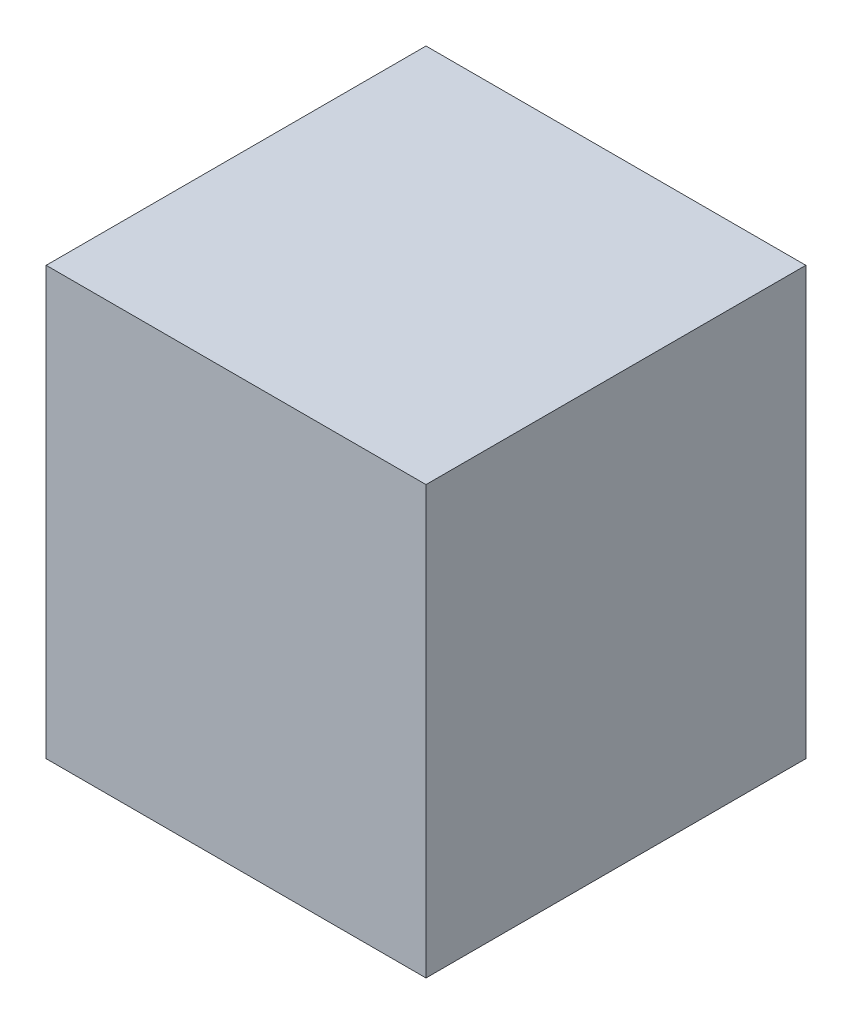
from build123d import *

# Parameters (mm, degrees)
SKETCH1_W           = 101.6
SKETCH1_H           = 101.6
BOSS_EXTRUDE1_DEPTH = 114.3


with BuildPart() as part:
    # Sketch1 → Boss-Extrude1 (new body)
    with BuildSketch(Plane(origin=(0, 0, 0), x_dir=(1, 0, 0), z_dir=(0, 1, 0))):
        Rectangle(SKETCH1_W, SKETCH1_H)
    extrude(amount=BOSS_EXTRUDE1_DEPTH)


solid = part.part
